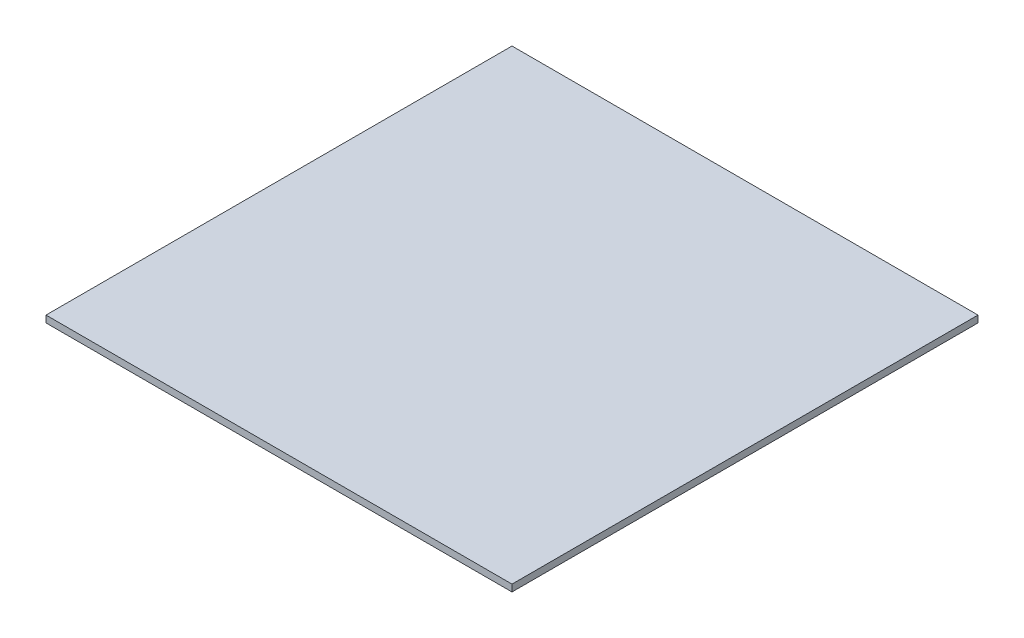
from build123d import *

# Parameters (mm, degrees)
SKETCH1_W           = 75
SKETCH1_H           = 75
BOSS_EXTRUDE1_DEPTH = 1.1


with BuildPart() as part:
    # Sketch1 → Boss-Extrude1 (new body)
    with BuildSketch(Plane(origin=(0, 0, 0), x_dir=(1, 0, 0), z_dir=(0, 1, 0))):
        Rectangle(SKETCH1_W, SKETCH1_H)
    extrude(amount=BOSS_EXTRUDE1_DEPTH)


solid = part.part
